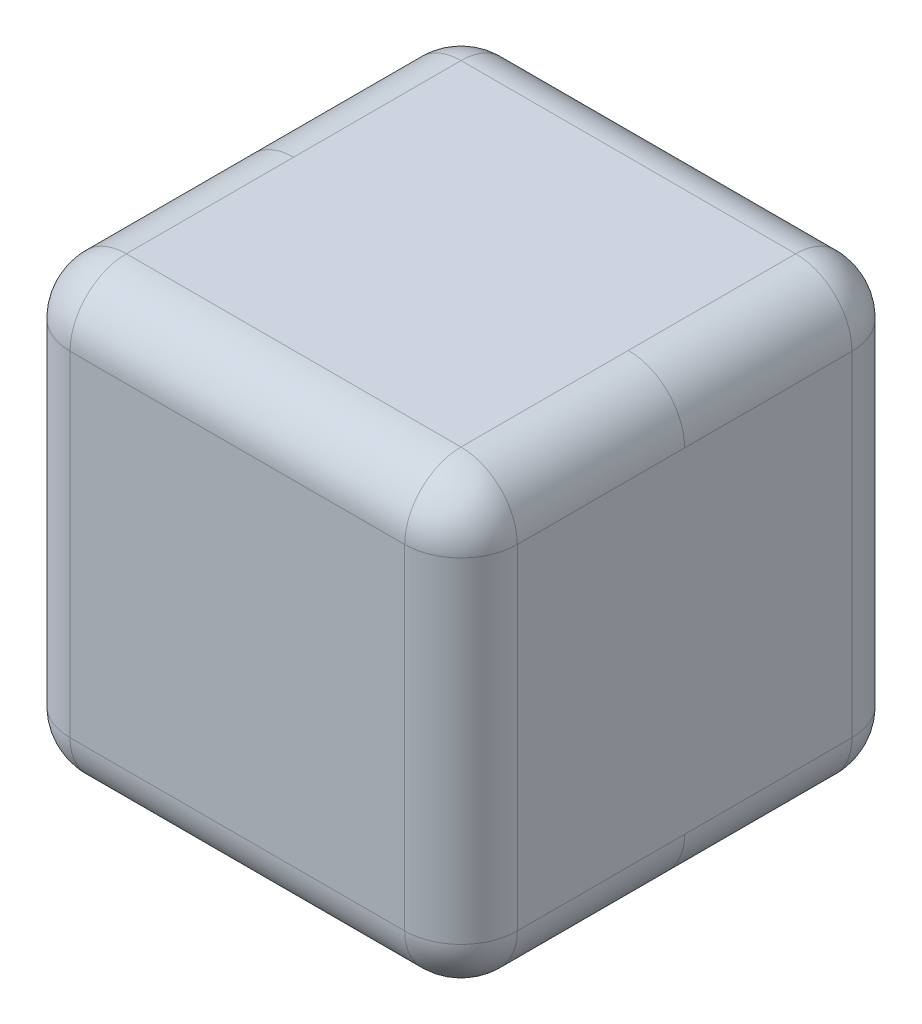
from build123d import *

# Parameters (mm, degrees)
BOSS_EXTRUDE1_DEPTH  = 147
FILLET1_R            = 18.5
CUT_EXTRUDE1_DEPTH   = 50
FILLET2_R            = 20
FILLET1_OF_MIRROR1_R = 18.5
FILLET2_OF_MIRROR1_R = 20


with BuildPart() as part:
    # Sketch1 → Boss-Extrude1 (new body)
    with BuildSketch(Plane(origin=(0, 0, 0), x_dir=(1, 0, 0), z_dir=(0, 1, 0))):
        Polygon((-73.50000000000001, 73.5), (73.5, 73.49999999999999), (73.50000000000001, 0), (-73.50000000000001, 0), align=None)
    boss_extrude1 = extrude(amount=BOSS_EXTRUDE1_DEPTH)

    # Fillet1
    fillet1_edges = [part.edges().sort_by_distance(p)[0] for p in [
        (73.5, 147, -36.74999999999999),
        (-1.421e-14, 147, -73.5),
        (-73.50000000000001, 147, -36.75),
        (-1.421e-14, 0, -73.5),
        (73.5, 0, -36.74999999999999),
        (-73.50000000000001, 0, -36.75),
        (-73.50000000000001, 73.5, -73.5),
        (73.5, 73.5, -73.49999999999999),
    ]]
    fillet(fillet1_edges, radius=FILLET1_R)

    # Sketch2 → Cut-Extrude1 (cut)
    with BuildSketch(Plane.XY):
        Polygon((-50.00000000000003, 137), (49.99999999999997, 137.00000000000006), (50.00000000000007, 2.000000000000012), (-50.00000000000004, 2), align=None)
    cut_extrude1 = extrude(amount=-CUT_EXTRUDE1_DEPTH, mode=Mode.SUBTRACT)

    # Fillet2
    fillet2_edges = [part.edges().sort_by_distance(p)[0] for p in [
        (-50.000000000000036, 69.5, -50),
        (-50.00000000000004, 2, -25),
        (-2.842e-14, 137.00000000000003, -50),
        (-50.00000000000003, 137, -25),
        (50.00000000000002, 69.50000000000003, -50),
        (49.99999999999997, 137.00000000000006, -25),
        (1.421e-14, 2.000000000000006, -50),
        (50.00000000000007, 2.000000000000012, -25),
    ]]
    fillet(fillet2_edges, radius=FILLET2_R)

    # Mirror1: Boss-Extrude1, Cut-Extrude1 across plane
    add(boss_extrude1.mirror(Plane(origin=(-73.50000000000001, 147, 0), x_dir=(1, 0, 0), z_dir=(0, 0, -1))))
    add(cut_extrude1.mirror(Plane(origin=(-73.50000000000001, 147, 0), x_dir=(1, 0, 0), z_dir=(0, 0, -1))), mode=Mode.SUBTRACT)

    # Fillet1 of Mirror1
    fillet1_of_mirror1_edges = [part.edges().sort_by_distance(p)[0] for p in [
        (73.5, 147, 36.74999999999999),
        (-1.421e-14, 147, 73.5),
        (-73.50000000000001, 147, 36.75),
        (-1.421e-14, 0, 73.5),
        (73.5, 0, 36.74999999999999),
        (-73.50000000000001, 0, 36.75),
        (-73.50000000000001, 73.5, 73.5),
        (73.5, 73.5, 73.49999999999999),
    ]]
    fillet(fillet1_of_mirror1_edges, radius=FILLET1_OF_MIRROR1_R)

    # Fillet2 of Mirror1
    fillet2_of_mirror1_edges = [part.edges().sort_by_distance(p)[0] for p in [
        (-50.000000000000036, 69.5, 50),
        (-50.00000000000004, 2, 25),
        (-2.842e-14, 137.00000000000003, 50),
        (-50.00000000000003, 137, 25),
        (50.00000000000002, 69.50000000000003, 50),
        (49.99999999999997, 137.00000000000006, 25),
        (1.421e-14, 2.000000000000006, 50),
        (50.00000000000007, 2.000000000000012, 25),
    ]]
    fillet(fillet2_of_mirror1_edges, radius=FILLET2_OF_MIRROR1_R)


solid = part.part
